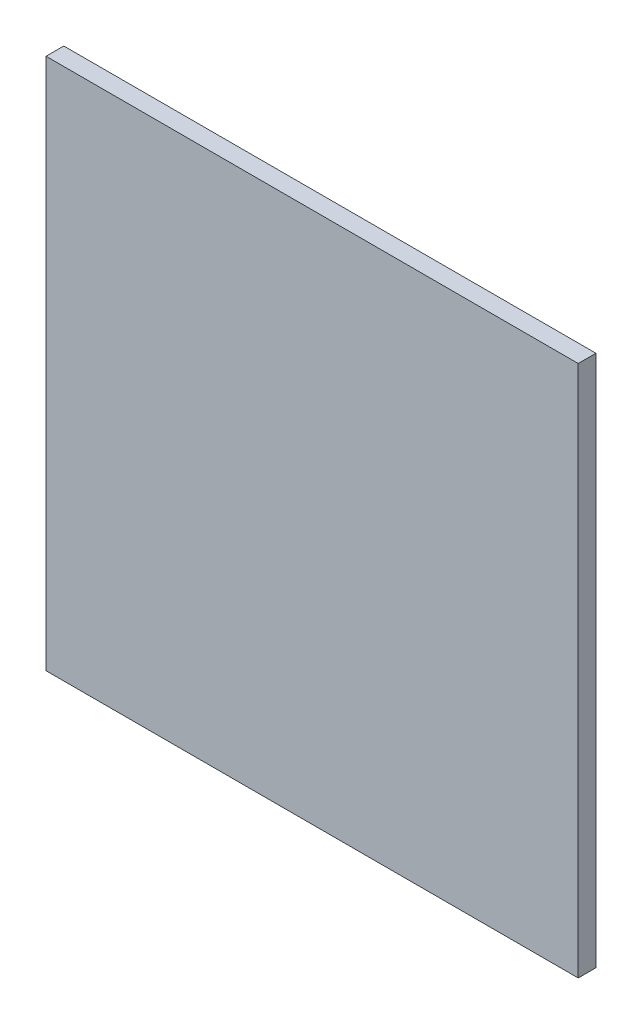
from build123d import *

# Parameters (mm, degrees)
ESBO_O1_W                = 300
ESBO_O1_H                = 300
RESSALTO_EXTRUS_O1_DEPTH = 10


with BuildPart() as part:
    # Esboço1 → Ressalto-extrusão1 (new body)
    with BuildSketch(Plane.XY):
        with Locations((68.691155295, -137.077702703)):
            Rectangle(ESBO_O1_W, ESBO_O1_H)
    extrude(amount=RESSALTO_EXTRUS_O1_DEPTH)


solid = part.part
